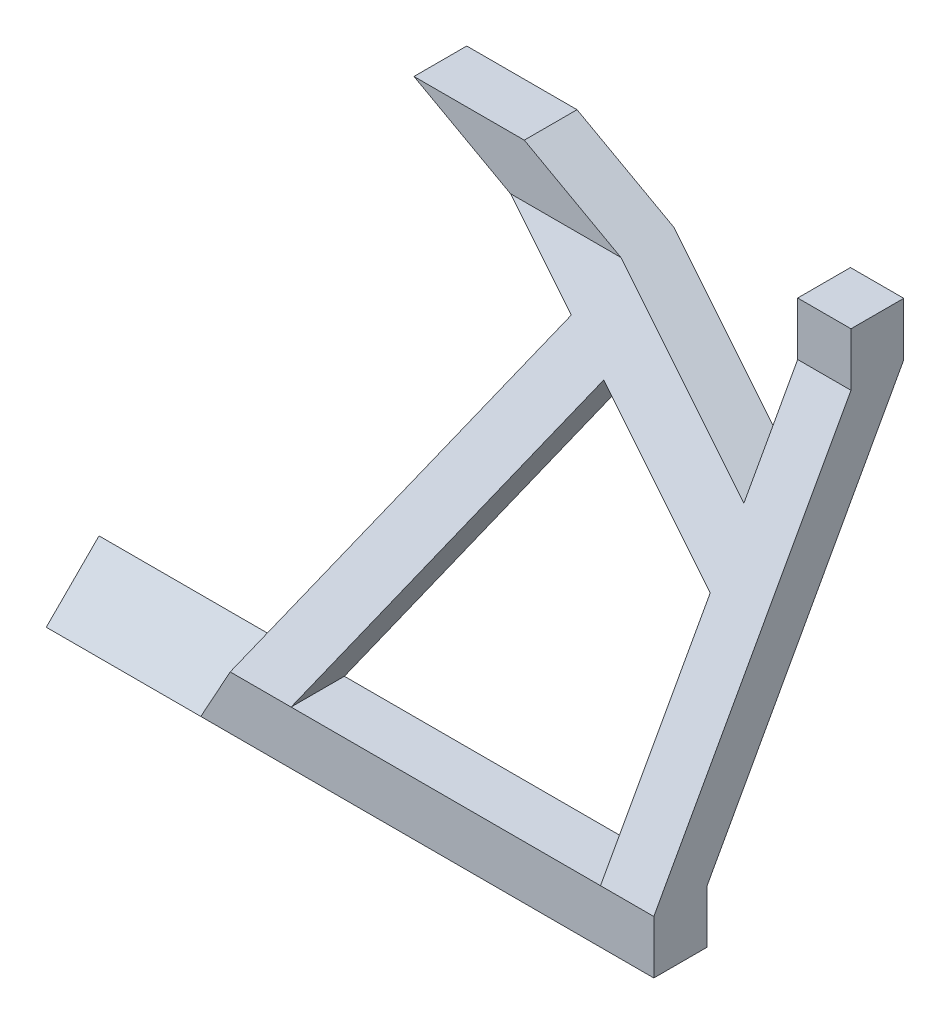
from build123d import *

# Parameters (mm, degrees)
SKETCH8_W               = 85
SKETCH8_H               = 10
BOSS_EXTRUDE4_DEPTH     = 10
SKETCH9_W               = 82
SKETCH9_H               = 9.9
BOSS_EXTRUDE5_DEPTH     = 10
CUT_EXTRUDE2_DEPTH      = 176.278228509
CUT_EXTRUDE2_DEPTH_BACK = 176.278228509
BOSS_EXTRUDE6_DEPTH     = 114


with BuildPart() as part:
    # Sketch8 → Boss-Extrude4 (new body)
    with BuildSketch(Plane(origin=(0, 0, 0), x_dir=(1, 0, 0), z_dir=(0, 1, 0))):
        with Locations((90.205142442, -69.45)):
            Rectangle(SKETCH8_W, SKETCH8_H)
    extrude(amount=BOSS_EXTRUDE4_DEPTH)


with BuildPart() as body_2:
    # Sketch9 → Boss-Extrude5 (new body)
    with BuildSketch(Plane(origin=(0, 87, 0), x_dir=(1, 0, 0), z_dir=(0, 1, 0))):
        with Locations((91.705142442, -32.5)):
            Rectangle(SKETCH9_W, SKETCH9_H)
    extrude(amount=-BOSS_EXTRUDE5_DEPTH)


    add(part.part)  # loft1 joins it to this body
    # loft from a face of the part (loft1)
    loft([body_2.faces().sort_by_distance((91.705142442, 77, 32.5))[0], body_2.faces().sort_by_distance((90.205142442, 10, 69.45))[0]])

    # Sketch1 → Cut-Extrude2 (cut, two sides)
    with BuildSketch(Plane.XY) as cut_extrude2_sk:
        Polygon((122.705142442, 87), (71.403683768, 87), (122.705142442, 58.6920409), align=None)
        Polygon((64.644486366, 10), (93.961994057, 63.13102594), (122.705142442, 47.270660759), (122.705142442, 10), align=None)
        Polygon((47.705142442, 0), (40.860670667, 0), (50.705142442, 87), (85.206484761, 67.96228426), align=None)
    extrude(amount=CUT_EXTRUDE2_DEPTH, mode=Mode.SUBTRACT)
    extrude(cut_extrude2_sk.sketch, amount=-CUT_EXTRUDE2_DEPTH_BACK, mode=Mode.SUBTRACT)

    # Sketch10 → Boss-Extrude6 (add)
    with BuildSketch(Plane(origin=(132.705142442, 0, 0), x_dir=(0, 0, -1), z_dir=(1, 0, 0))):
        Polygon((-64.55, 9.9), (-64.55, 0), (-74.45, 0), align=None)
    extrude(amount=-BOSS_EXTRUDE6_DEPTH)


solid = body_2.part
